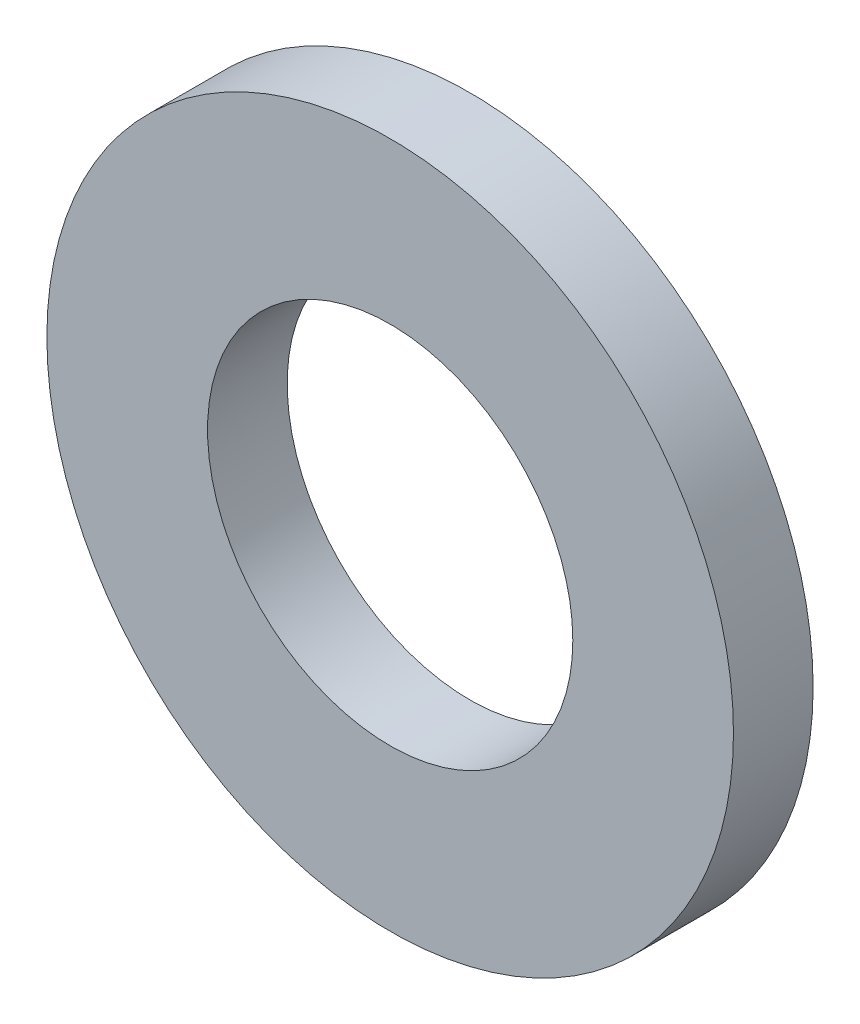
from build123d import *

# Parameters (mm, degrees)
SKETCH1_R           = 6.35
SKETCH1_R_2         = 3.3782
BOSS_EXTRUDE1_DEPTH = 1.4732


with BuildPart() as part:
    # Sketch1 → Boss-Extrude1 (new body)
    with BuildSketch(Plane.XY):
        Circle(SKETCH1_R)
        Circle(SKETCH1_R_2, mode=Mode.SUBTRACT)
    extrude(amount=BOSS_EXTRUDE1_DEPTH)


solid = part.part
